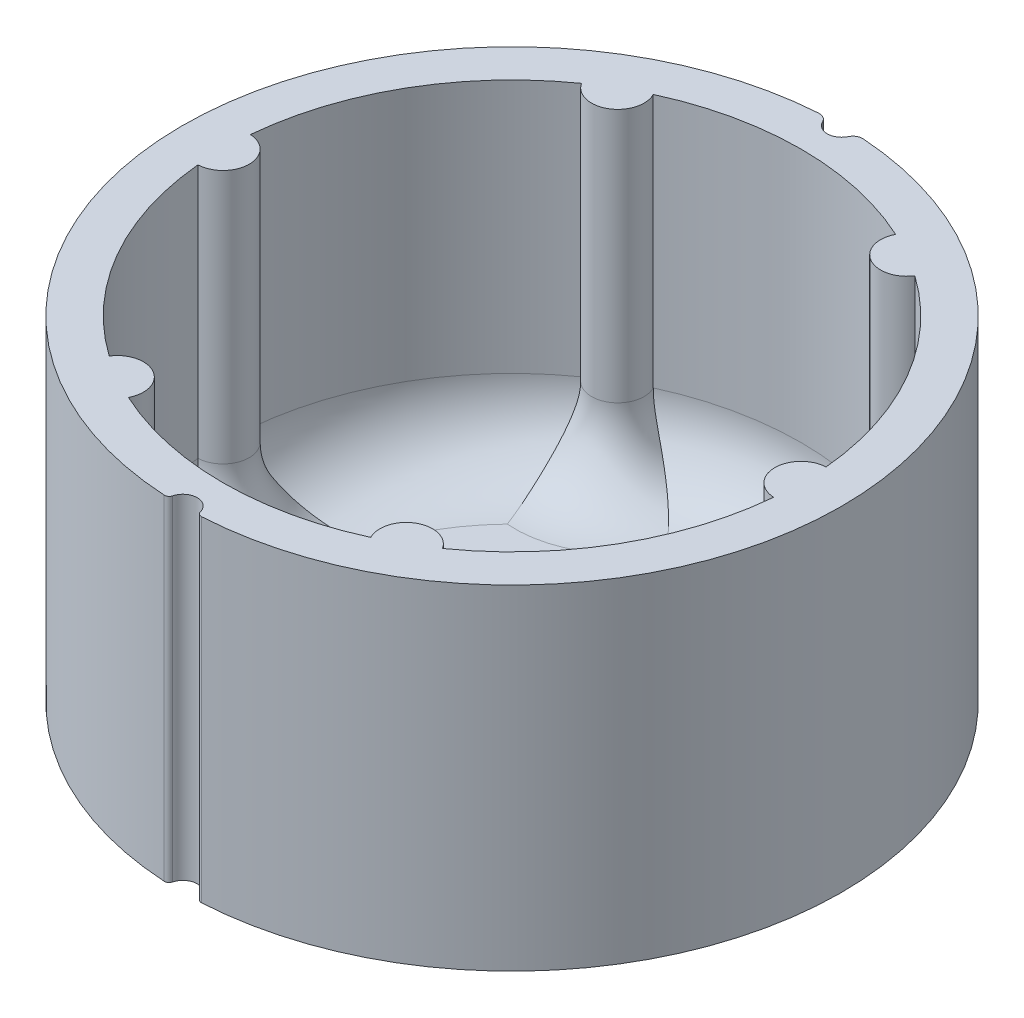
from build123d import *

# Parameters (mm, degrees)
BOSS_EXTRUDE1_DEPTH = 35
CUT_EXTRUDE2_DEPTH  = 61.012997416
BOSS_EXTRUDE2_DEPTH = 0.4
FILLET1_R           = 8


with BuildPart() as part:
    # Sketch1 → Boss-Extrude1 (new body)
    with BuildSketch(Plane(origin=(0, 0, 0), x_dir=(1, 0, 0), z_dir=(0, 1, 0))):
        with BuildLine():
            ThreePointArc((1.451818925, -34.068556857), (1.641248992, -34.346908706), (1.964225605, -34.442038138))
            ThreePointArc((1.964225605, -34.442038138), (26.591847487, -21.978073076), (34.198225299, 4.555174015))
            ThreePointArc((34.198225299, 4.555174015), (23.590291339, 25.176355888), (2.324135821, 34.423627607))
            ThreePointArc((2.324135821, 34.423627607), (1.751838249, 34.289058819), (1.354061739, 33.856153382))
            ThreePointArc((1.354061739, 33.856153382), (0, 33.001534515), (-1.354061739, 33.856153382))
            ThreePointArc((-1.354061739, 33.856153382), (-1.751838249, 34.289058819), (-2.324135821, 34.423627607))
            ThreePointArc((-2.324135821, 34.423627607), (-23.590291339, 25.176355888), (-34.198225299, 4.555174015))
            ThreePointArc((-34.198225299, 4.555174015), (-26.591847487, -21.978073076), (-1.964225605, -34.442038138))
            ThreePointArc((-1.964225605, -34.442038138), (-1.641248992, -34.346908706), (-1.451818925, -34.068556857))
            ThreePointArc((-1.451818925, -34.068556857), (0, -32.945679925), (1.451818925, -34.068556857))
        make_face()
        with BuildLine():
            Line((-2.417, 3.787737139), (0, 3.787737139))
            Line((0, 3.787737139), (2.417, 3.787737139))
            ThreePointArc((2.417, 3.787737139), (0, -4.489512172), (-2.417, 3.787737139))
        make_face(mode=Mode.SUBTRACT)
    extrude(amount=BOSS_EXTRUDE1_DEPTH)

    # Sketch2 → Cut-Extrude2 (cut, through all)
    with BuildSketch(Plane(origin=(0, 0, 0), x_dir=(1, 0, 0), z_dir=(0, 1, 0))):
        with BuildLine():
            ThreePointArc((-17.441608289, 24.715436478), (-26.197268464, 15.125), (-30.125, 2.747157622))
            ThreePointArc((-30.125, 2.747157622), (-27.5, 0), (-30.125, -2.747157622))
            ThreePointArc((-30.125, -2.747157622), (-26.197268464, -15.125), (-17.441608289, -24.715436478))
            ThreePointArc((-17.441608289, -24.715436478), (-13.75, -23.815698604), (-12.683391711, -27.4625941))
            ThreePointArc((-12.683391711, -27.4625941), (0, -30.25), (12.683391711, -27.4625941))
            ThreePointArc((12.683391711, -27.4625941), (13.75, -23.815698604), (17.441608289, -24.715436478))
            ThreePointArc((17.441608289, -24.715436478), (26.197268464, -15.125), (30.125, -2.747157622))
            ThreePointArc((30.125, -2.747157622), (27.5, 0), (30.125, 2.747157622))
            ThreePointArc((30.125, 2.747157622), (26.197268464, 15.125), (17.441608289, 24.715436478))
            ThreePointArc((17.441608289, 24.715436478), (13.75, 23.815698604), (12.683391711, 27.4625941))
            ThreePointArc((12.683391711, 27.4625941), (0, 30.25), (-12.683391711, 27.4625941))
            ThreePointArc((-12.683391711, 27.4625941), (-13.75, 23.815698604), (-17.441608289, 24.715436478))
        make_face()
    extrude(amount=CUT_EXTRUDE2_DEPTH, mode=Mode.SUBTRACT)

    # Sketch2_2 → Boss-Extrude2 (add)
    with BuildSketch(Plane(origin=(0, 0, 0), x_dir=(1, 0, 0), z_dir=(0, 1, 0))):
        with BuildLine():
            ThreePointArc((-17.441608289, 24.715436478), (-26.197268464, 15.125), (-30.125, 2.747157622))
            ThreePointArc((-30.125, 2.747157622), (-27.5, 0), (-30.125, -2.747157622))
            ThreePointArc((-30.125, -2.747157622), (-26.197268464, -15.125), (-17.441608289, -24.715436478))
            ThreePointArc((-17.441608289, -24.715436478), (-13.75, -23.815698604), (-12.683391711, -27.4625941))
            ThreePointArc((-12.683391711, -27.4625941), (0, -30.25), (12.683391711, -27.4625941))
            ThreePointArc((12.683391711, -27.4625941), (13.75, -23.815698604), (17.441608289, -24.715436478))
            ThreePointArc((17.441608289, -24.715436478), (26.197268464, -15.125), (30.125, -2.747157622))
            ThreePointArc((30.125, -2.747157622), (27.5, 0), (30.125, 2.747157622))
            ThreePointArc((30.125, 2.747157622), (26.197268464, 15.125), (17.441608289, 24.715436478))
            ThreePointArc((17.441608289, 24.715436478), (13.75, 23.815698604), (12.683391711, 27.4625941))
            ThreePointArc((12.683391711, 27.4625941), (0, 30.25), (-12.683391711, 27.4625941))
            ThreePointArc((-12.683391711, 27.4625941), (-13.75, 23.815698604), (-17.441608289, 24.715436478))
        make_face()
    extrude(amount=BOSS_EXTRUDE2_DEPTH)

    # Fillet1
    fillet1_edges = [part.edges().sort_by_distance(p)[0] for p in [
        (13.75, 0.4, 23.815698604),
        (0, 0.4, 30.25),
        (-13.75, 0.4, 23.815698604),
        (-26.197268464, 0.4, 15.125),
        (-27.5, 0.4, 0),
        (-26.197268464, 0.4, -15.125),
        (-13.75, 0.4, -23.815698604),
        (0, 0.4, -30.25),
        (13.75, 0.4, -23.815698604),
        (26.197268464, 0.4, -15.125),
        (27.5, 0.4, 0),
        (26.197268464, 0.4, 15.125),
    ]]
    fillet(fillet1_edges, radius=FILLET1_R)


solid = part.part
